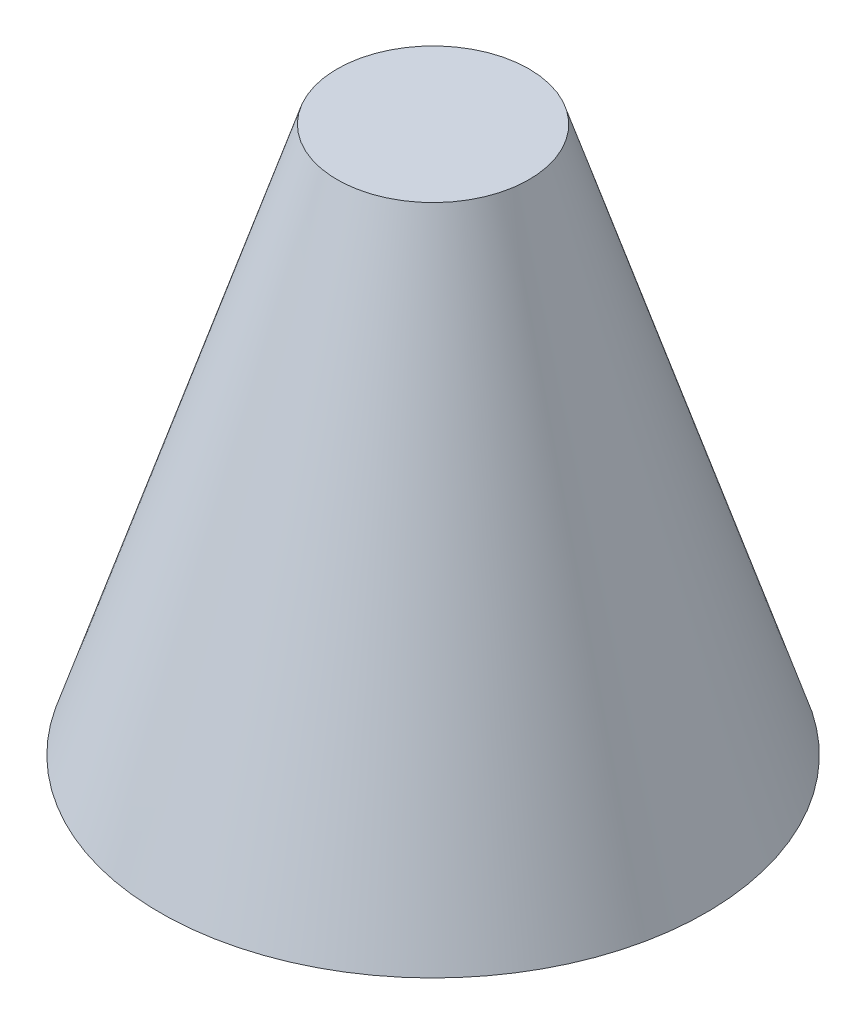
from build123d import *


with BuildPart() as part:
    # 草图2 → 旋转1 (revolve)
    with BuildSketch(Plane.XY):
        Polygon((0, -0.545321134), (0, 73.454678866), (13, 73.454678866), (37, -0.545321134), align=None)
    revolve(axis=Axis((0, -0.545321134, 0), (0, 1, 0)))


solid = part.part
